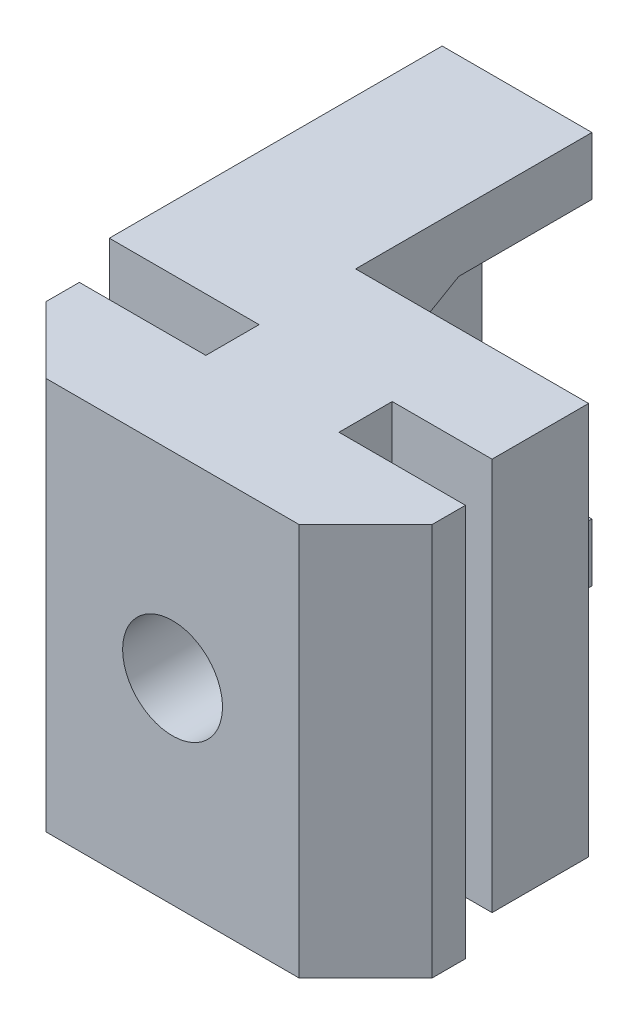
from build123d import *

# Parameters (mm, degrees)
BOSS_EXTRUDE1_DEPTH      = 25
CUT_EXTRUDE1_REACH       = 27
M3_TAPPED_HOLE1_D        = 3
M3_TAPPED_HOLE1_DEPTH    = 7.5
M4_CLEARANCE_HOLE1_D     = 4.5
M4_CLEARANCE_HOLE1_DEPTH = 4.5
CUT_EXTRUDE2_DEPTH       = 3.3
SKETCH9_W                = 12.3
SKETCH9_H                = 6.6
CUT_EXTRUDE3_DEPTH       = 15.6


with BuildPart() as part:
    # Sketch1 → Boss-Extrude1 (new body)
    with BuildSketch(Plane(origin=(0, 0, 0), x_dir=(1, 0, 0), z_dir=(0, 1, 0))):
        Polygon((-3.8, 0), (-5.8, 2), (-5.8, 3), (-2, 3), (-2, 4.6), (-6.5, 4.6), (-6.5, 14.6), (6.5, 14.6), (6.5, 4.6), (2, 4.6), (2, 3), (5.8, 3), (5.8, 2), (3.8, 0), align=None)
    extrude(amount=BOSS_EXTRUDE1_DEPTH)

    # Sketch2 → Cut-Extrude1 (cut, up to next)
    with BuildSketch(Plane(origin=(0, 25, 0), x_dir=(1, 0, 0), z_dir=(0, 1, 0)), mode=Mode.PRIVATE) as cut_extrude1_sk1:
        Polygon((6.5, 4.6), (5, 4.6), (5, 7.5), (-2, 7.5), (-2, 14.6), (6.5, 14.6), align=None)
    cut_extrude1_tool1 = extrude(cut_extrude1_sk1.sketch, amount=-CUT_EXTRUDE1_REACH, mode=Mode.PRIVATE) & part.part
    add(cut_extrude1_tool1.solids().sort_by_distance((2.485317, 25, -10.713833))[0], mode=Mode.SUBTRACT)

    # M3 Tapped Hole1
    with Locations(Plane(origin=(0, 0, -7.5), x_dir=(-1, 0, 0), z_dir=(0, 0, -1))):
        with Locations((0, 22), (0, 3), (0, 12.5)):
            Hole(M3_TAPPED_HOLE1_D / 2, depth=M3_TAPPED_HOLE1_DEPTH)

    # M4 Clearance Hole1
    with Locations(Plane.ZY.offset(6.5)):
        with Locations((-10.6, 12.5)):
            Hole(M4_CLEARANCE_HOLE1_D / 2, depth=M4_CLEARANCE_HOLE1_DEPTH)

    # Sketch8 → Cut-Extrude2 (cut)
    with BuildSketch(Plane(origin=(-2, 0, 0), x_dir=(0, 0, -1), z_dir=(1, 0, 0))):
        Polygon((10.6, 16.656921938), (14.6, 16.656921938), (14.6, 8.343078062), (10.6, 8.343078062), (7, 10.421539031), (7, 14.578460969), align=None)
    extrude(amount=-CUT_EXTRUDE2_DEPTH, mode=Mode.SUBTRACT)

    # Sketch9 → Cut-Extrude3 (cut, through all)
    with BuildSketch(Plane(origin=(0, 0, -14.6), x_dir=(-1, 0, 0), z_dir=(0, 0, -1))):
        with Locations((0.35, 21.7)):
            Rectangle(SKETCH9_W, SKETCH9_H)
        with Locations((0.35, 3.3)):
            Rectangle(SKETCH9_W, SKETCH9_H)
    extrude(amount=-CUT_EXTRUDE3_DEPTH, mode=Mode.SUBTRACT)


solid = part.part
